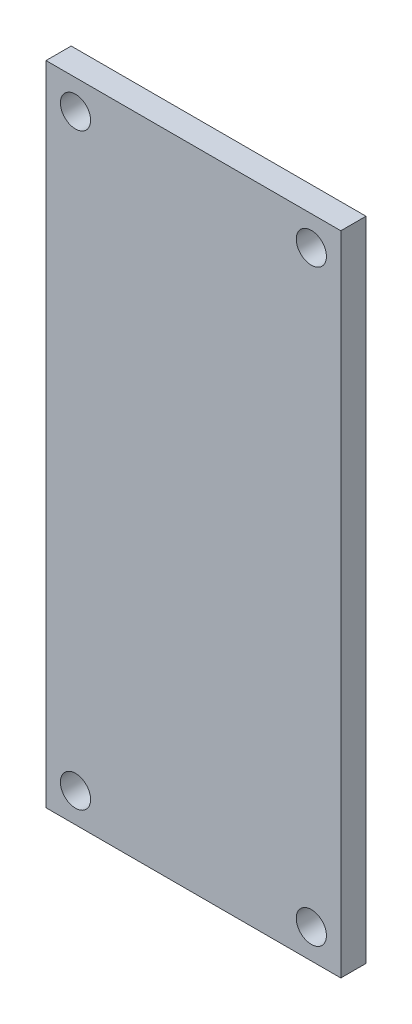
from build123d import *

# Parameters (mm, degrees)
SKETCH1_W          = 20.5
SKETCH1_H          = 45
EXTRUDE1_DEPTH     = 1.75
SKETCH2_R          = 1.05
CUT_EXTRUDE1_DEPTH = 1.75


with BuildPart() as part:
    # Sketch1 → Extrude1 (new body)
    with BuildSketch(Plane.XY):
        Rectangle(SKETCH1_W, SKETCH1_H)
    extrude(amount=EXTRUDE1_DEPTH)

    # Sketch2 → Cut-Extrude1 (cut)
    with BuildSketch(Plane.XY.offset(1.75)):
        with Locations((8.2, -20.45)):
            Circle(SKETCH2_R)
        with Locations((-8.2, 20.45)):
            Circle(SKETCH2_R)
        with Locations((-8.2, -20.45)):
            Circle(SKETCH2_R)
        with Locations((8.2, 20.45)):
            Circle(SKETCH2_R)
    extrude(amount=-CUT_EXTRUDE1_DEPTH, mode=Mode.SUBTRACT)


solid = part.part
